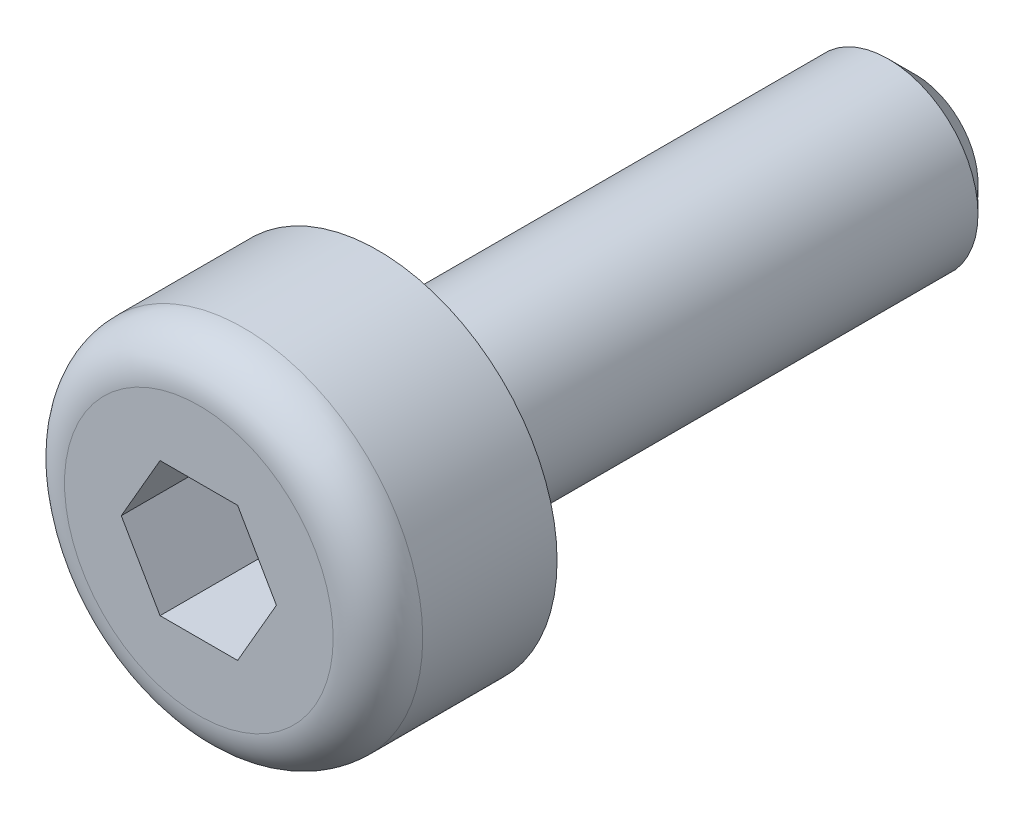
from build123d import *

# Parameters (mm, degrees)
SKICA1_R                 = 2
P_IDAT_VYSUNUT_M1_DEPTH  = 2
ODEBRAT_VYSUNUT_M1_DEPTH = 2
SKICA2_R                 = 1
P_IDAT_VYSUNUT_M2_DEPTH  = 6
ZKOSEN_1_SIZE            = 0.3
ZAOBLIT1_R               = 0.5


with BuildPart() as part:
    # Skica1 → Přidat vysunutím1 (new body)
    with BuildSketch(Plane.XY):
        Circle(SKICA1_R)
    extrude(amount=P_IDAT_VYSUNUT_M1_DEPTH)

    # Skica4 → Odebrat vysunutím1 (cut)
    with BuildSketch(Plane.XY.offset(2)):
        Polygon((-0.866025404, 0), (-0.433012702, -0.75), (0.433012702, -0.75), (0.866025404, 0), (0.433012702, 0.75), (-0.433012702, 0.75), align=None)
    extrude(amount=-ODEBRAT_VYSUNUT_M1_DEPTH, mode=Mode.SUBTRACT)

    # Skica2 → Přidat vysunutím2 (add)
    with BuildSketch(Plane(origin=(0, 0, 0), x_dir=(-1, 0, 0), z_dir=(0, 0, -1))):
        Circle(SKICA2_R)
    extrude(amount=P_IDAT_VYSUNUT_M2_DEPTH)

    # Zkosení1
    zkosen_1_edges = [part.edges().sort_by_distance(p)[0] for p in [
        (1, 0, -6),
    ]]
    chamfer(zkosen_1_edges, length=ZKOSEN_1_SIZE)

    # Zaoblit1
    zaoblit1_edges = [part.edges().sort_by_distance(p)[0] for p in [
        (-2, 0, 2),
    ]]
    fillet(zaoblit1_edges, radius=ZAOBLIT1_R)


solid = part.part
